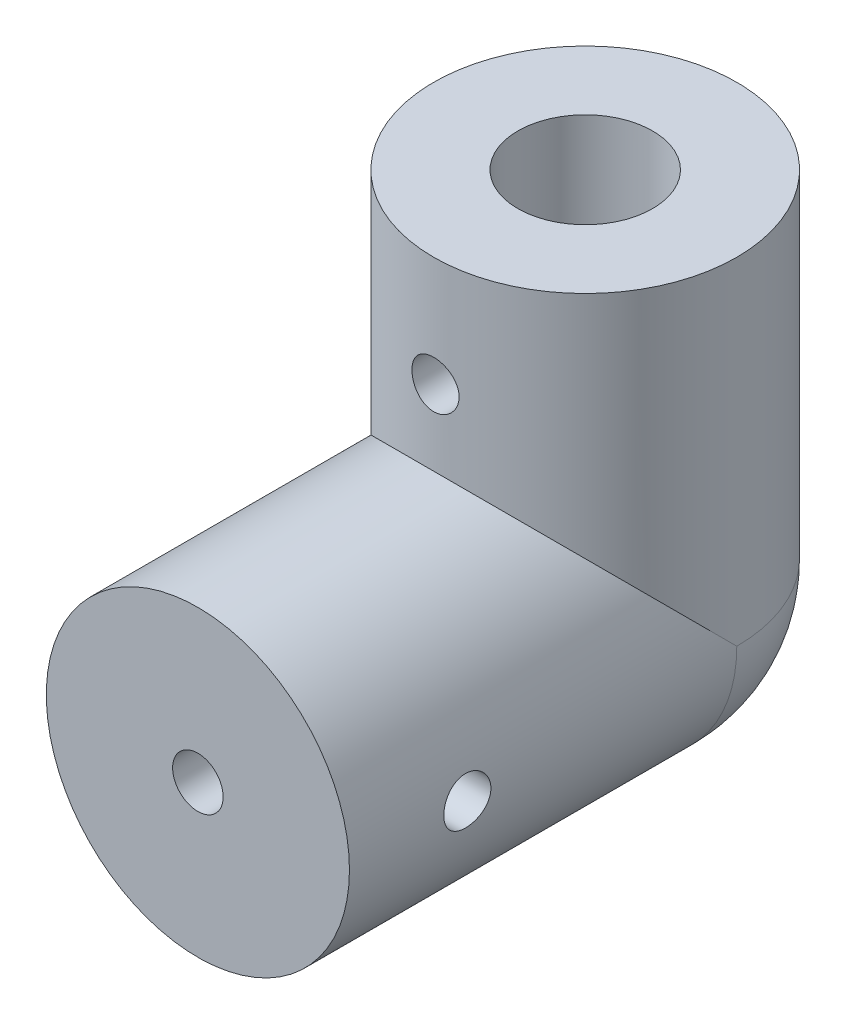
from build123d import *

# Parameters (mm, degrees)
CROQUIS1_R                   = 9
CROQUIS1_R_2                 = 1.5
SALIENTE_EXTRUIR1_DEPTH      = 15
SALIENTE_EXTRUIR1_DEPTH_BACK = 8
CROQUIS2_R                   = 9
CROQUIS2_R_2                 = 4
SALIENTE_EXTRUIR4_DEPTH      = 20
CROQUIS7_R                   = 4
CORTAR_EXTRUIR1_DEPTH        = 20
CROQUIS8_R                   = 1.5
CORTAR_EXTRUIR2_DEPTH        = 15
CROQUIS9_R                   = 1.4
CORTAR_EXTRUIR3_DEPTH        = 19
CROQUIS10_R                  = 1.4
CORTAR_EXTRUIR4_DEPTH        = 1
CORTAR_EXTRUIR4_DEPTH_BACK   = 33.0000001


with BuildPart() as part:
    # Croquis1 → Saliente-Extruir1 (new body, two sides)
    with BuildSketch(Plane.XY) as saliente_extruir1_sk:
        Circle(CROQUIS1_R)
        Circle(CROQUIS1_R_2, mode=Mode.SUBTRACT)
    extrude(amount=SALIENTE_EXTRUIR1_DEPTH)
    extrude(saliente_extruir1_sk.sketch, amount=-SALIENTE_EXTRUIR1_DEPTH_BACK)

    # Croquis2 → Saliente-Extruir4 (add)
    with BuildSketch(Plane(origin=(0, 0, 0), x_dir=(1, 0, 0), z_dir=(0, 1, 0))):
        with Locations((0, 8)):
            Circle(CROQUIS2_R)
        with Locations((0, 8)):
            Circle(CROQUIS2_R_2, mode=Mode.SUBTRACT)
    extrude(amount=SALIENTE_EXTRUIR4_DEPTH)

    # Croquis6 → Revolución4 (revolve)
    with BuildSketch(Plane(origin=(0, 0, -8), x_dir=(-1, 0, 0), z_dir=(0, 0, -1))):
        with BuildLine():
            Line((0, 0), (0, -9))
            ThreePointArc((0, -9), (-6.363961031, -6.363961031), (-9, 0))
            Line((-9, 0), (0, 0))
        make_face()
    revolve(axis=Axis((0, 0, -8), (0, -1, 0)))

    # Croquis7 → Cortar-Extruir1 (cut)
    with BuildSketch(Plane(origin=(0, 20, 0), x_dir=(1, 0, 0), z_dir=(0, 1, 0))):
        with Locations((0, 8)):
            Circle(CROQUIS7_R)
    extrude(amount=-CORTAR_EXTRUIR1_DEPTH, mode=Mode.SUBTRACT)

    # Croquis8 → Cortar-Extruir2 (cut)
    with BuildSketch(Plane.XY.offset(15)):
        Circle(CROQUIS8_R)
    extrude(amount=-CORTAR_EXTRUIR2_DEPTH, mode=Mode.SUBTRACT)

    # Croquis9 → Cortar-Extruir3 (cut, through all)
    with BuildSketch(Plane.ZY.offset(9)):
        with Locations((8, 0)):
            Circle(CROQUIS9_R)
    extrude(amount=-CORTAR_EXTRUIR3_DEPTH, mode=Mode.SUBTRACT)

    # Croquis10 → Cortar-Extruir4 (cut, two sides)
    with BuildSketch(Plane(origin=(0, 0, -17), x_dir=(-1, 0, 0), z_dir=(0, 0, -1))) as cortar_extruir4_sk:
        with Locations((0, 13.459047629)):
            Circle(CROQUIS10_R)
    extrude(amount=CORTAR_EXTRUIR4_DEPTH, mode=Mode.SUBTRACT)
    extrude(cortar_extruir4_sk.sketch, amount=-CORTAR_EXTRUIR4_DEPTH_BACK, mode=Mode.SUBTRACT)


solid = part.part
